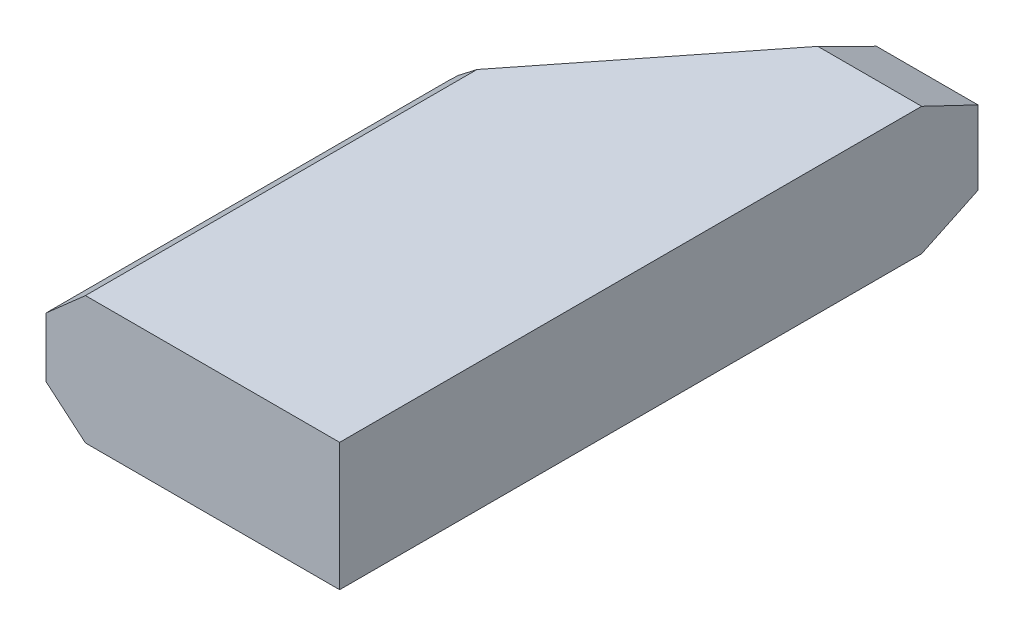
from build123d import *

# Parameters (mm, degrees)
SKETCH1_W           = 233.68
SKETCH1_H           = 101.6
BOSS_EXTRUDE1_DEPTH = 508
CUT_EXTRUDE1_DEPTH  = 569.324645251
CUT_EXTRUDE2_DEPTH  = 569.324645251
CUT_EXTRUDE3_DEPTH  = 569.324645251
CUT_EXTRUDE4_DEPTH  = 538.880617648


with BuildPart() as part:
    # Sketch1 → Boss-Extrude1 (new body)
    with BuildSketch(Plane.XY):
        with Locations((-116.84, 50.8)):
            Rectangle(SKETCH1_W, SKETCH1_H)
    extrude(amount=-BOSS_EXTRUDE1_DEPTH)

    # Sketch2 → Cut-Extrude1 (cut, through all)
    with BuildSketch(Plane.XY):
        Polygon((-202.283526953, 101.6), (-233.68, 73.908067848), (-233.68, 101.6), align=None)
        Polygon((-202.283526953, 0), (-233.68, 26.611014762), (-233.68, 0), align=None)
    extrude(amount=-CUT_EXTRUDE1_DEPTH, mode=Mode.SUBTRACT)

    # Sketch3 → Cut-Extrude2 (cut, through all)
    with BuildSketch(Plane(origin=(0, 101.6, 0), x_dir=(1, 0, 0), z_dir=(0, 1, 0))):
        Polygon((-87.070770682, 508), (-233.68, 321.585732495), (-233.68, 508), align=None)
    extrude(amount=-CUT_EXTRUDE2_DEPTH, mode=Mode.SUBTRACT)

    # Sketch4 → Cut-Extrude3 (cut, through all)
    with BuildSketch(Plane(origin=(0, 0, 0), x_dir=(0, 0, -1), z_dir=(1, 0, 0))):
        Polygon((463.161638797, 101.6), (508, 80.157516446), (508, 101.6), align=None)
        Polygon((463.161638797, 0), (508, 21.319923331), (508, 0), align=None)
    extrude(amount=-CUT_EXTRUDE3_DEPTH, mode=Mode.SUBTRACT)

    # Sketch5 → Cut-Extrude4 (cut, through all)
    with BuildSketch(Plane(origin=(217.205760792, 0, -275.127297003), x_dir=(-0.7848827655334263, 1.8564028129682992e-15, -0.6196442885790207), z_dir=(0.6196442885790207, 2.3514435630931796e-15, -0.7848827655334263))):
        Polygon((351.862738174, 101.6), (383.119645888, 76.175565291), (383.013937726, 101.6), align=None)
        Polygon((383.119645888, 27.634188335), (351.862738174, 0), (383.013937726, 0), align=None)
    extrude(amount=-CUT_EXTRUDE4_DEPTH, mode=Mode.SUBTRACT)


with BuildPart() as cut_extrude4_kept_piece:
    # of the separate pieces the step leaves, the one the design keeps (cut_extrude4_pieces_kept)
    add(part.part.solids().sort_by_distance((0, 0, 0))[0])


solid = cut_extrude4_kept_piece.part
